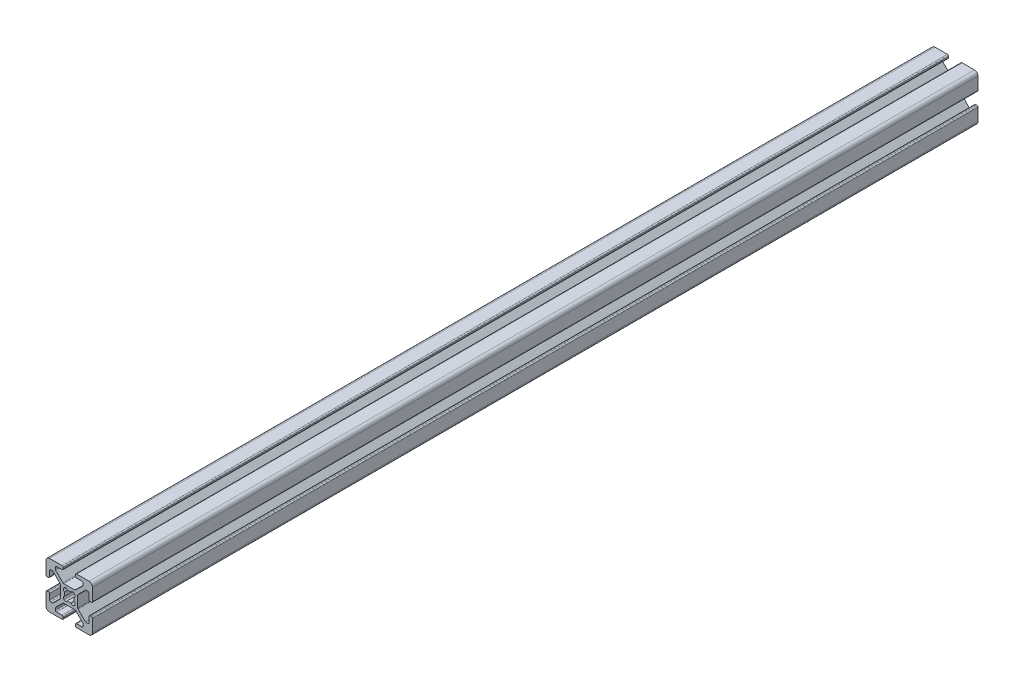
from build123d import *

# Parameters (mm, degrees)
BOSS_EXTRUDE1_DEPTH = 381


with BuildPart() as part:
    # Sketch1 → Boss-Extrude1 (new body)
    with BuildSketch(Plane(origin=(0, 0, -457.2), x_dir=(-1, 0, 0), z_dir=(0, 0, -1))):
        with BuildLine():
            Line((10, -8.5), (10, -3.138))
            ThreePointArc((10, -3.138), (9.851210245, -2.778789755), (9.492, -2.63))
            Line((9.492, -2.63), (9.008, -2.63))
            ThreePointArc((9.008, -2.63), (8.648789755, -2.778789755), (8.5, -3.138))
            Line((8.5, -3.138), (8.5, -5.487))
            ThreePointArc((8.5, -5.487), (8.351210245, -5.846210245), (7.992, -5.995))
            Line((7.992, -5.995), (7.26592049, -5.995))
            ThreePointArc((7.26592049, -5.995), (7.071517306, -5.956330803), (6.906710245, -5.846210245))
            Line((6.906710245, -5.846210245), (3.803789755, -2.743289755))
            ThreePointArc((3.803789755, -2.743289755), (3.693669197, -2.578482694), (3.655, -2.38407951))
            Line((3.655, -2.38407951), (3.655, 2.383759167))
            ThreePointArc((3.655, 2.383759167), (3.693669197, 2.57816235), (3.803789755, 2.742969412))
            Line((3.803789755, 2.742969412), (6.907030588, 5.846210245))
            ThreePointArc((6.907030588, 5.846210245), (7.07183765, 5.956330803), (7.266240833, 5.995))
            Line((7.266240833, 5.995), (7.992, 5.995))
            ThreePointArc((7.992, 5.995), (8.351210245, 5.846210245), (8.5, 5.487))
            Line((8.5, 5.487), (8.5, 3.138))
            ThreePointArc((8.5, 3.138), (8.648789755, 2.778789755), (9.008, 2.63))
            Line((9.008, 2.63), (9.492, 2.63))
            ThreePointArc((9.492, 2.63), (9.851210245, 2.778789755), (10, 3.138))
            Line((10, 3.138), (10, 8.5))
            ThreePointArc((10, 8.5), (9.560660172, 9.560660172), (8.5, 10))
            Line((8.5, 10), (3.138, 10))
            ThreePointArc((3.138, 10), (2.778789755, 9.851210245), (2.63, 9.492))
            Line((2.63, 9.492), (2.63, 9.008))
            ThreePointArc((2.63, 9.008), (2.778789755, 8.648789755), (3.138, 8.5))
            Line((3.138, 8.5), (5.487, 8.5))
            ThreePointArc((5.487, 8.5), (5.846210245, 8.351210245), (5.995, 7.992))
            Line((5.995, 7.992), (5.995, 7.26592049))
            ThreePointArc((5.995, 7.26592049), (5.956330803, 7.071517306), (5.846210245, 6.906710245))
            Line((5.846210245, 6.906710245), (2.743289755, 3.803789755))
            ThreePointArc((2.743289755, 3.803789755), (2.578482694, 3.693669197), (2.38407951, 3.655))
            Line((2.38407951, 3.655), (-2.383759167, 3.655))
            ThreePointArc((-2.383759167, 3.655), (-2.57816235, 3.693669197), (-2.742969412, 3.803789755))
            Line((-2.742969412, 3.803789755), (-5.846210245, 6.907030588))
            ThreePointArc((-5.846210245, 6.907030588), (-5.956330803, 7.07183765), (-5.995, 7.266240833))
            Line((-5.995, 7.266240833), (-5.995, 7.992))
            ThreePointArc((-5.995, 7.992), (-5.846210245, 8.351210245), (-5.487, 8.5))
            Line((-5.487, 8.5), (-3.138, 8.5))
            ThreePointArc((-3.138, 8.5), (-2.778789755, 8.648789755), (-2.63, 9.008))
            Line((-2.63, 9.008), (-2.63, 9.492))
            ThreePointArc((-2.63, 9.492), (-2.778789755, 9.851210245), (-3.138, 10))
            Line((-3.138, 10), (-8.5, 10))
            ThreePointArc((-8.5, 10), (-9.560660172, 9.560660172), (-10, 8.5))
            Line((-10, 8.5), (-10, 3.138))
            ThreePointArc((-10, 3.138), (-9.851210245, 2.778789755), (-9.492, 2.63))
            Line((-9.492, 2.63), (-9.008, 2.63))
            ThreePointArc((-9.008, 2.63), (-8.648789755, 2.778789755), (-8.5, 3.138))
            Line((-8.5, 3.138), (-8.5, 5.487))
            ThreePointArc((-8.5, 5.487), (-8.351210245, 5.846210245), (-7.992, 5.995))
            Line((-7.992, 5.995), (-7.26592049, 5.995))
            ThreePointArc((-7.26592049, 5.995), (-7.071517306, 5.956330803), (-6.906710245, 5.846210245))
            Line((-6.906710245, 5.846210245), (-3.803789755, 2.743289755))
            ThreePointArc((-3.803789755, 2.743289755), (-3.693669197, 2.578482694), (-3.655, 2.38407951))
            Line((-3.655, 2.38407951), (-3.655, -2.383759167))
            ThreePointArc((-3.655, -2.383759167), (-3.693669197, -2.57816235), (-3.803789755, -2.742969412))
            Line((-3.803789755, -2.742969412), (-6.907030588, -5.846210245))
            ThreePointArc((-6.907030588, -5.846210245), (-7.07183765, -5.956330803), (-7.266240833, -5.995))
            Line((-7.266240833, -5.995), (-7.992, -5.995))
            ThreePointArc((-7.992, -5.995), (-8.351210245, -5.846210245), (-8.5, -5.487))
            Line((-8.5, -5.487), (-8.5, -3.138))
            ThreePointArc((-8.5, -3.138), (-8.648789755, -2.778789755), (-9.008, -2.63))
            Line((-9.008, -2.63), (-9.492, -2.63))
            ThreePointArc((-9.492, -2.63), (-9.851210245, -2.778789755), (-10, -3.138))
            Line((-10, -3.138), (-10, -8.5))
            ThreePointArc((-10, -8.5), (-9.560660172, -9.560660172), (-8.5, -10))
            Line((-8.5, -10), (-3.138, -10))
            ThreePointArc((-3.138, -10), (-2.778789755, -9.851210245), (-2.63, -9.492))
            Line((-2.63, -9.492), (-2.63, -9.008))
            ThreePointArc((-2.63, -9.008), (-2.778789755, -8.648789755), (-3.138, -8.5))
            Line((-3.138, -8.5), (-5.487, -8.5))
            ThreePointArc((-5.487, -8.5), (-5.846210245, -8.351210245), (-5.995, -7.992))
            Line((-5.995, -7.992), (-5.995, -7.26592049))
            ThreePointArc((-5.995, -7.26592049), (-5.956330803, -7.071517306), (-5.846210245, -6.906710245))
            Line((-5.846210245, -6.906710245), (-2.743289755, -3.803789755))
            ThreePointArc((-2.743289755, -3.803789755), (-2.578482694, -3.693669197), (-2.38407951, -3.655))
            Line((-2.38407951, -3.655), (2.383759167, -3.655))
            ThreePointArc((2.383759167, -3.655), (2.57816235, -3.693669197), (2.742969412, -3.803789755))
            Line((2.742969412, -3.803789755), (5.846210245, -6.907030588))
            ThreePointArc((5.846210245, -6.907030588), (5.956330803, -7.07183765), (5.995, -7.266240833))
            Line((5.995, -7.266240833), (5.995, -7.992))
            ThreePointArc((5.995, -7.992), (5.846210245, -8.351210245), (5.487, -8.5))
            Line((5.487, -8.5), (3.138, -8.5))
            ThreePointArc((3.138, -8.5), (2.778789755, -8.648789755), (2.63, -9.008))
            Line((2.63, -9.008), (2.63, -9.492))
            ThreePointArc((2.63, -9.492), (2.778789755, -9.851210245), (3.138, -10))
            Line((3.138, -10), (8.5, -10))
            ThreePointArc((8.5, -10), (9.560660172, -9.560660172), (10, -8.5))
        make_face()
        with BuildLine():
            Line((2.304493037, -2.124493037), (2.124493037, -2.304493037))
            ThreePointArc((2.124493037, -2.304493037), (1.35638567, -2.506016078), (0.803729988, -1.935777391))
            ThreePointArc((0.803729988, -1.935777391), (0, -2.096), (-0.803729988, -1.935777391))
            ThreePointArc((-0.803729988, -1.935777391), (-1.35638567, -2.506016078), (-2.124493037, -2.304493037))
            Line((-2.124493037, -2.304493037), (-2.304493037, -2.124493037))
            ThreePointArc((-2.304493037, -2.124493037), (-2.506016078, -1.35638567), (-1.935777391, -0.803729988))
            ThreePointArc((-1.935777391, -0.803729988), (-2.096, 0), (-1.935777391, 0.803729988))
            ThreePointArc((-1.935777391, 0.803729988), (-2.506016078, 1.35638567), (-2.304493037, 2.124493037))
            Line((-2.304493037, 2.124493037), (-2.124493037, 2.304493037))
            ThreePointArc((-2.124493037, 2.304493037), (-1.35638567, 2.506016078), (-0.803729988, 1.935777391))
            ThreePointArc((-0.803729988, 1.935777391), (0, 2.096), (0.803729988, 1.935777391))
            ThreePointArc((0.803729988, 1.935777391), (1.35638567, 2.506016078), (2.124493037, 2.304493037))
            Line((2.124493037, 2.304493037), (2.304493037, 2.124493037))
            ThreePointArc((2.304493037, 2.124493037), (2.506016078, 1.35638567), (1.935777391, 0.803729988))
            ThreePointArc((1.935777391, 0.803729988), (2.096, 0), (1.935777391, -0.803729988))
            ThreePointArc((1.935777391, -0.803729988), (2.506016078, -1.35638567), (2.304493037, -2.124493037))
        make_face(mode=Mode.SUBTRACT)
    extrude(amount=-BOSS_EXTRUDE1_DEPTH)


solid = part.part
